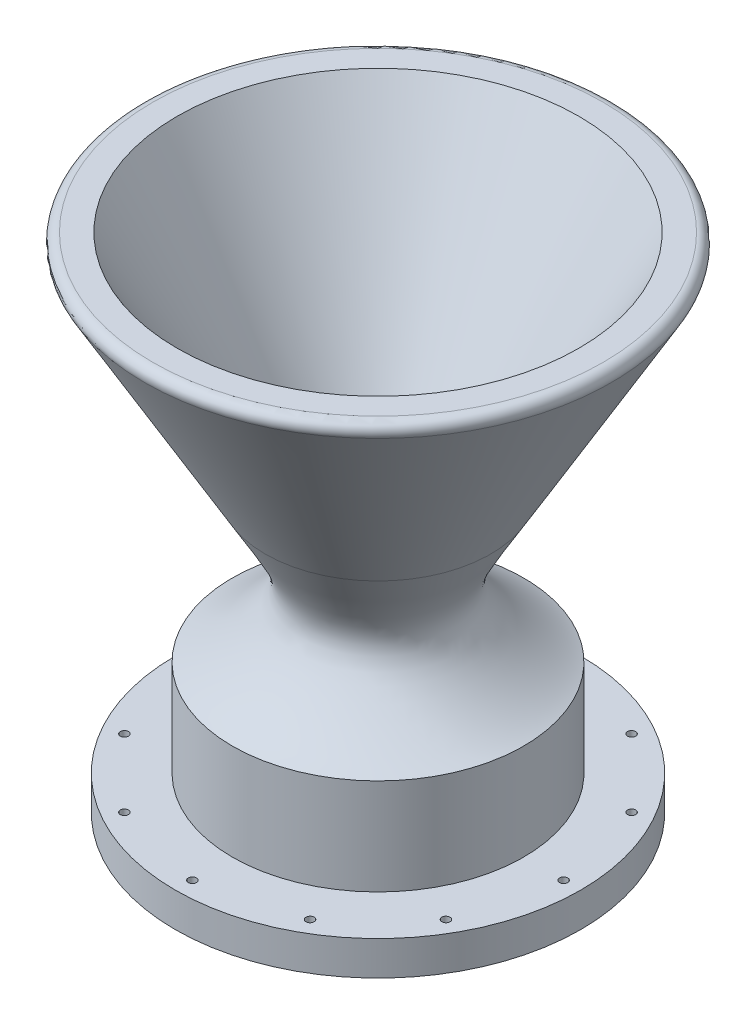
from build123d import *

# Parameters (mm, degrees)
TAP_DRILL_FOR_4_40_TAP1_REACH  = 195.495
TAP_DRILL_FOR_4_40_TAP1_BORE_R = 1.1303
CIRPATTERN2_COUNT              = 12


with BuildPart() as part:
    # Sketch2 → Revolve1 (revolve)
    with BuildSketch(Plane.XY, mode=Mode.PRIVATE) as revolve1_sk:
        with BuildLine():
            Line((0, 0), (56.388, 0))
            Line((56.388, 0), (56.388, 9.525))
            Line((56.388, 9.525), (40.513, 9.525))
            Line((40.513, 9.525), (40.513, 36.273710772))
            add(Edge.make_bspline(
                [(31.350017752, 77.94108456), (21.994739884, 61.495552558), (14.496239106, 54.512025578), (35.025537779, 38.606321532), (40.513, 36.273710772)],
                knots=[0, 0, 0, 0, 0.510148534, 0.739608491, 0.739608491, 0.739608491, 0.739608491], degree=3))
            Line((31.350017752, 77.94108456), (64.855703913, 135.974635332))
            ThreePointArc((64.855703913, 135.974635332), (64.855703913, 138.514635332), (62.655999387, 139.784635332))
            Line((62.655999387, 139.784635332), (55.88, 139.784635332))
            Line((55.88, 139.784635332), (6.35, 53.996158833))
            Line((6.35, 53.996158833), (6.35, 41.296158833))
            Line((6.35, 41.296158833), (21.780496632, 32.387357449))
            Line((21.780496632, 32.387357449), (21.780496632, 6.35))
            Line((21.780496632, 6.35), (0, 6.35))
            Line((0, 6.35), (0, 0))
        make_face()
    revolve(revolve1_sk.sketch.rotate(Axis((0, 6.35, 0), (0, -1, 0)), 90), axis=Axis((0, 6.35, 0), (0, -1, 0)))

    # Tap Drill for #4-40 Tap1 bore (on position points) → Tap Drill for #4-40 Tap1 (cut, up to next)
    with BuildSketch(Plane(origin=(0, 0, 51.6382), x_dir=(0, 0, -1), z_dir=(0, -1, 0)), mode=Mode.PRIVATE) as tap_drill_for_4_40_tap1_sk1:
        Circle(TAP_DRILL_FOR_4_40_TAP1_BORE_R)
    tap_drill_for_4_40_tap1_tool1 = extrude(tap_drill_for_4_40_tap1_sk1.sketch, amount=-TAP_DRILL_FOR_4_40_TAP1_REACH, mode=Mode.PRIVATE) & part.part
    tap_drill_for_4_40_tap1 = tap_drill_for_4_40_tap1_tool1.solids().sort_by_distance((0, 0, 51.6382))[0]
    add(tap_drill_for_4_40_tap1, mode=Mode.SUBTRACT)

    # CirPattern2: Tap Drill for #4-40 Tap1 ×12 about axis
    cirpattern2_axis = Axis((0, 0, 0), (0, 1, 0))
    for i in range(1, CIRPATTERN2_COUNT):
        add(tap_drill_for_4_40_tap1.rotate(cirpattern2_axis, i * 360 / CIRPATTERN2_COUNT), mode=Mode.SUBTRACT)


solid = part.part
